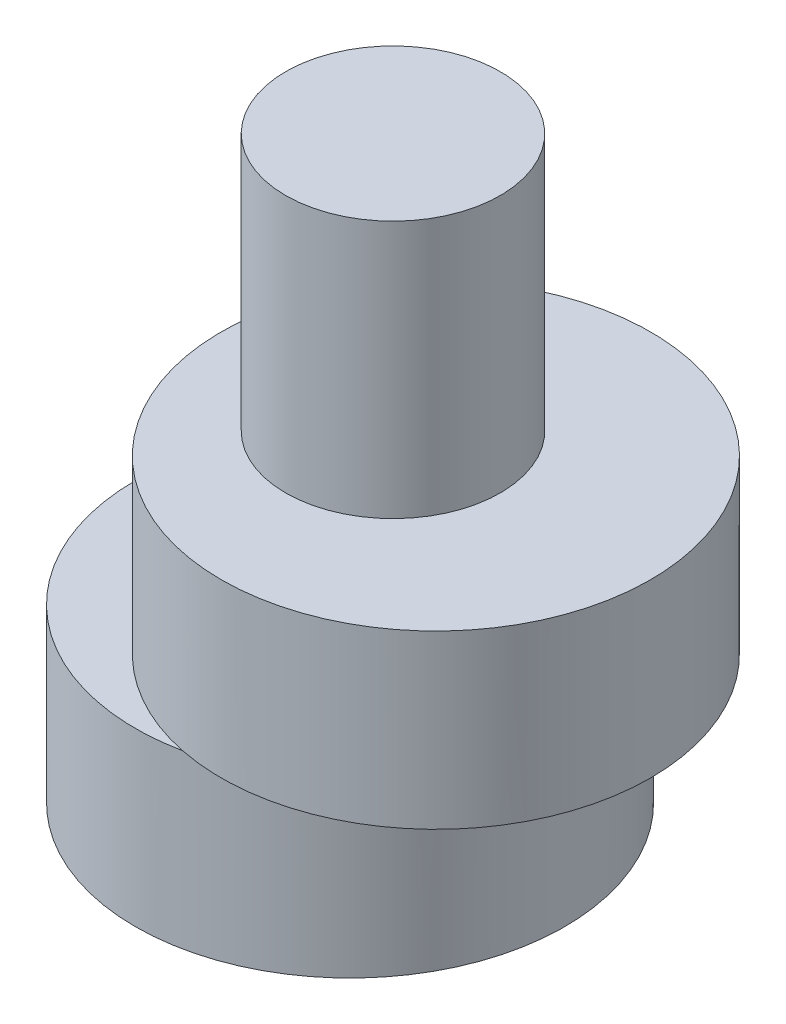
from build123d import *

# Parameters (mm, degrees)
SKETCH1_R           = 5
SKETCH1_R_2         = 3
BOSS_EXTRUDE1_DEPTH = 4
SKETCH2_R           = 5
BOSS_EXTRUDE2_DEPTH = 4
SKETCH3_R           = 2.5
BOSS_EXTRUDE3_DEPTH = 6
SKETCH4_R           = 3
CUT_EXTRUDE1_DEPTH  = 2
BOSS_EXTRUDE4_DEPTH = 6


with BuildPart() as part:
    # Sketch1 → Boss-Extrude1 (new body)
    with BuildSketch(Plane(origin=(0, 0, 0), x_dir=(1, 0, 0), z_dir=(0, 1, 0))):
        with Locations((-1, 0)):
            Circle(SKETCH1_R)
        Circle(SKETCH1_R_2, mode=Mode.SUBTRACT)
    extrude(amount=BOSS_EXTRUDE1_DEPTH)

    # Sketch2 → Boss-Extrude2 (add)
    with BuildSketch(Plane(origin=(0, 4, 0), x_dir=(1, 0, 0), z_dir=(0, 1, 0))):
        with Locations((1, 0)):
            Circle(SKETCH2_R)
    extrude(amount=BOSS_EXTRUDE2_DEPTH)

    # Sketch3 → Boss-Extrude3 (add)
    with BuildSketch(Plane(origin=(0, 8, 0), x_dir=(1, 0, 0), z_dir=(0, 1, 0))):
        Circle(SKETCH3_R)
    extrude(amount=BOSS_EXTRUDE3_DEPTH)

    # Sketch4 → Cut-Extrude1 (cut)
    with BuildSketch(Plane.XZ.offset(-4)):
        Circle(SKETCH4_R)
    extrude(amount=-CUT_EXTRUDE1_DEPTH, mode=Mode.SUBTRACT)

    # Sketch6 → Boss-Extrude4 (add, through all)
    with BuildSketch(Plane.XZ.offset(-6)):
        with BuildLine():
            ThreePointArc((3, 0), (2.711088342, 1.284523258), (1.9, 2.321637353))
            Line((1.9, 2.321637353), (1.9, -2.321637353))
            ThreePointArc((1.9, -2.321637353), (2.711088342, -1.284523258), (3, 0))
        make_face()
    extrude(amount=BOSS_EXTRUDE4_DEPTH)


solid = part.part
